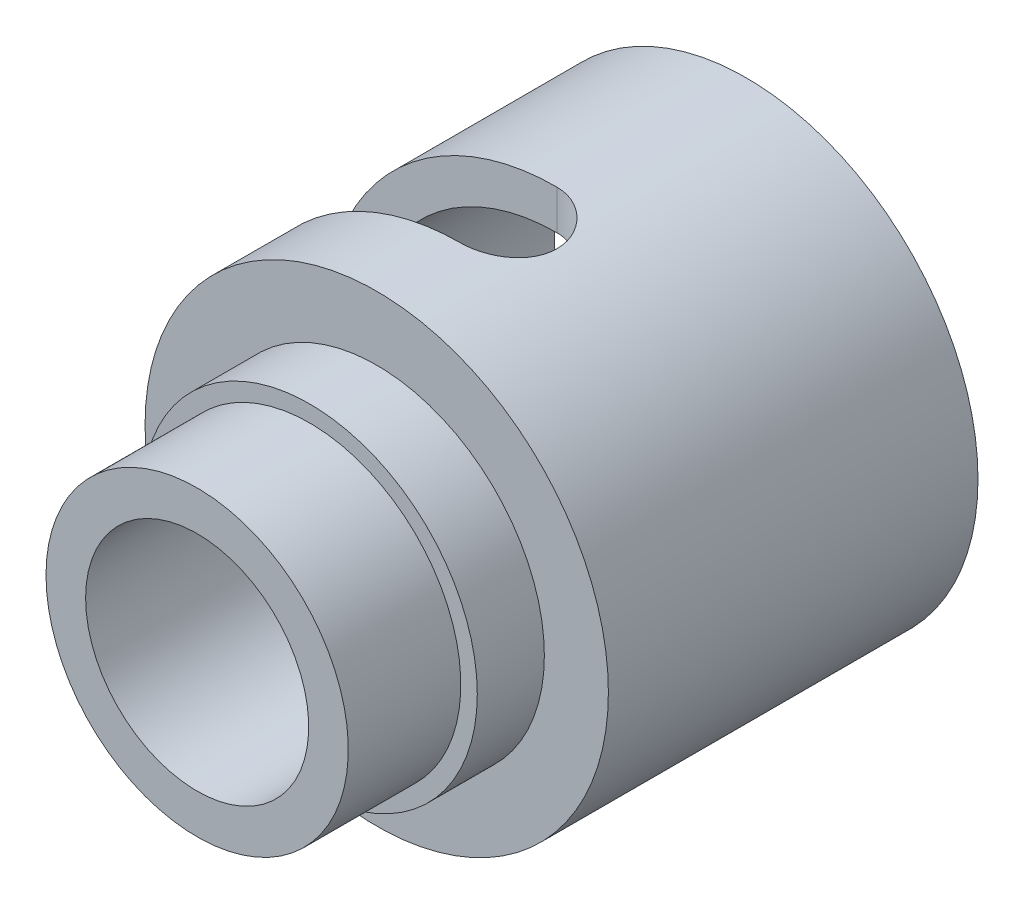
from build123d import *

# Parameters (mm, degrees)
SKETCH2_R          = 1.8288
CUT_EXTRUDE1_DEPTH = 9.7754
SKETCH3_R          = 1.8288
CUT_EXTRUDE2_DEPTH = 9.7754001
CUT_EXTRUDE3_DEPTH = 3.6576


with BuildPart() as part:
    # Sketch1 → Revolve1 (revolve)
    with BuildSketch(Plane(origin=(0, 0, 0), x_dir=(0, 0, -1), z_dir=(1, 0, 0)), mode=Mode.PRIVATE) as revolve1_sk:
        Polygon((0, 5.725), (0, 4.225), (7.802, 4.225), (7.802, 7.2754), (20.802, 7.2754), (20.802, 8.7754), (6.802, 8.7754), (6.802, 6.35), (4.262, 6.35), (4.262, 5.725), align=None)
    revolve(revolve1_sk.sketch.rotate(Axis((0, 0, 0), (0, 0, 1)), 90), axis=Axis((0, 0, 0), (0, 0, 1)))  # turned: the seam where the file's is

    # Sketch2 → Cut-Extrude1 (cut, through all)
    with BuildSketch(Plane(origin=(0, 0, 0), x_dir=(1, 0, 0), z_dir=(0, 1, 0))):
        with Locations(Location((0, 11.802, 0), (0, 0, 90))):  # turned: the seam where the file's is
            Circle(SKETCH2_R)
    extrude(amount=CUT_EXTRUDE1_DEPTH, mode=Mode.SUBTRACT)

    # Sketch3 → Cut-Extrude2 (cut, through all)
    with BuildSketch(Plane(origin=(0, 0, 0), x_dir=(0, 0, -1), z_dir=(1, 0, 0))):
        with Locations((11.802, 0)):
            Circle(SKETCH3_R)
    extrude(amount=-CUT_EXTRUDE2_DEPTH, mode=Mode.SUBTRACT)

    # Sketch4 → Cut-Extrude3 (cut)
    with BuildSketch(Plane(origin=(0, 0, -9.9732), x_dir=(-1, 0, 0), z_dir=(0, 0, -1))):
        with BuildLine():
            Line((0, 0), (0, 8.7754))
            ThreePointArc((0, 8.7754), (6.205144848, 6.205144848), (8.7754, 0))
            Line((8.7754, 0), (0, 0))
        make_face()
    extrude(amount=CUT_EXTRUDE3_DEPTH, mode=Mode.SUBTRACT)


solid = part.part
